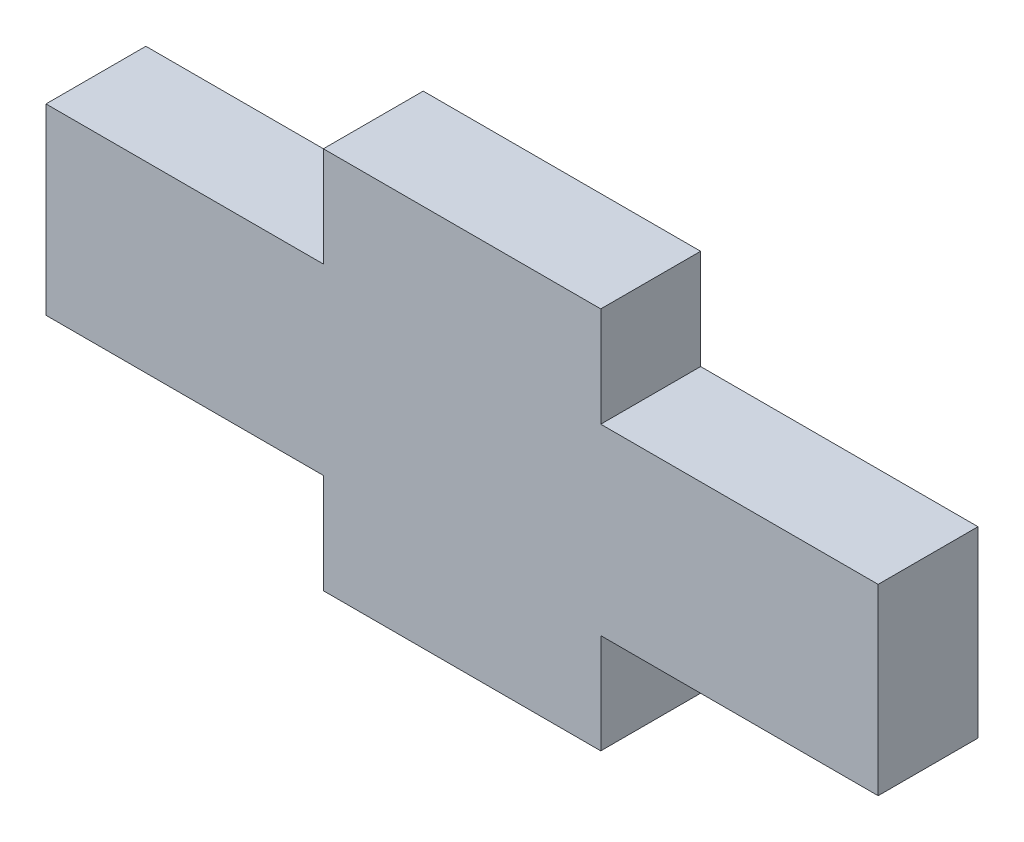
from build123d import *

# Parameters (mm, degrees)
BOSS_EXTRUDE1_DEPTH = 6.096


with BuildPart() as part:
    # Sketch1 → Boss-Extrude1 (new body)
    with BuildSketch(Plane.XY):
        Polygon((33.866666667, 11.176), (50.8, 11.176), (50.8, 0), (33.866666667, 0), (33.866666667, -6.096), (16.933333333, -6.096), (16.933333333, 0), (0, 0), (0, 11.176), (16.933333333, 11.176), (16.933333333, 17.272), (33.866666667, 17.272), align=None)
    extrude(amount=BOSS_EXTRUDE1_DEPTH)


solid = part.part
